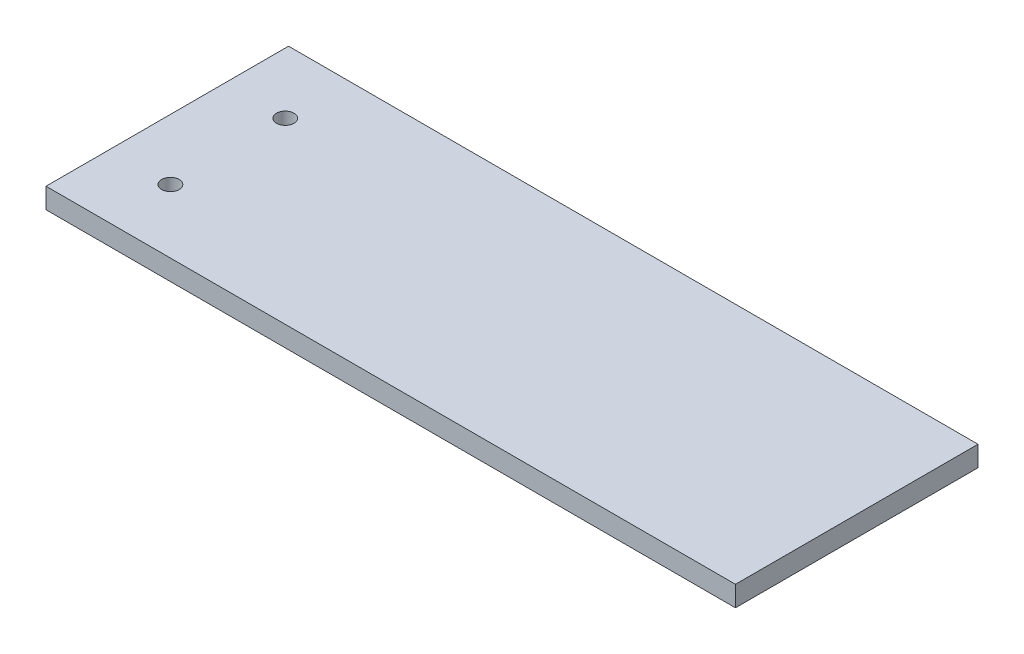
from build123d import *

# Parameters (mm, degrees)
SKETCH1_W           = 216.256477903
SKETCH1_H           = 76.077868368
BOSS_EXTRUDE1_DEPTH = 6.4
SKETCH2_R           = 2.75
CUT_EXTRUDE1_DEPTH  = 10


with BuildPart() as part:
    # Sketch1 → Boss-Extrude1 (new body)
    with BuildSketch(Plane(origin=(0, 0, 0), x_dir=(1, 0, 0), z_dir=(0, 1, 0))):
        with Locations((85.41776647, 23.975642843)):
            Rectangle(SKETCH1_W, SKETCH1_H)
    extrude(amount=BOSS_EXTRUDE1_DEPTH)

    # Sketch2 → Cut-Extrude1 (cut)
    with BuildSketch(Plane.XZ):
        with Locations((-3.660472482, -5.914577027)):
            Circle(SKETCH2_R)
        with Locations((-3.660472482, -41.914577027)):
            Circle(SKETCH2_R)
    extrude(amount=-CUT_EXTRUDE1_DEPTH, mode=Mode.SUBTRACT)


solid = part.part
